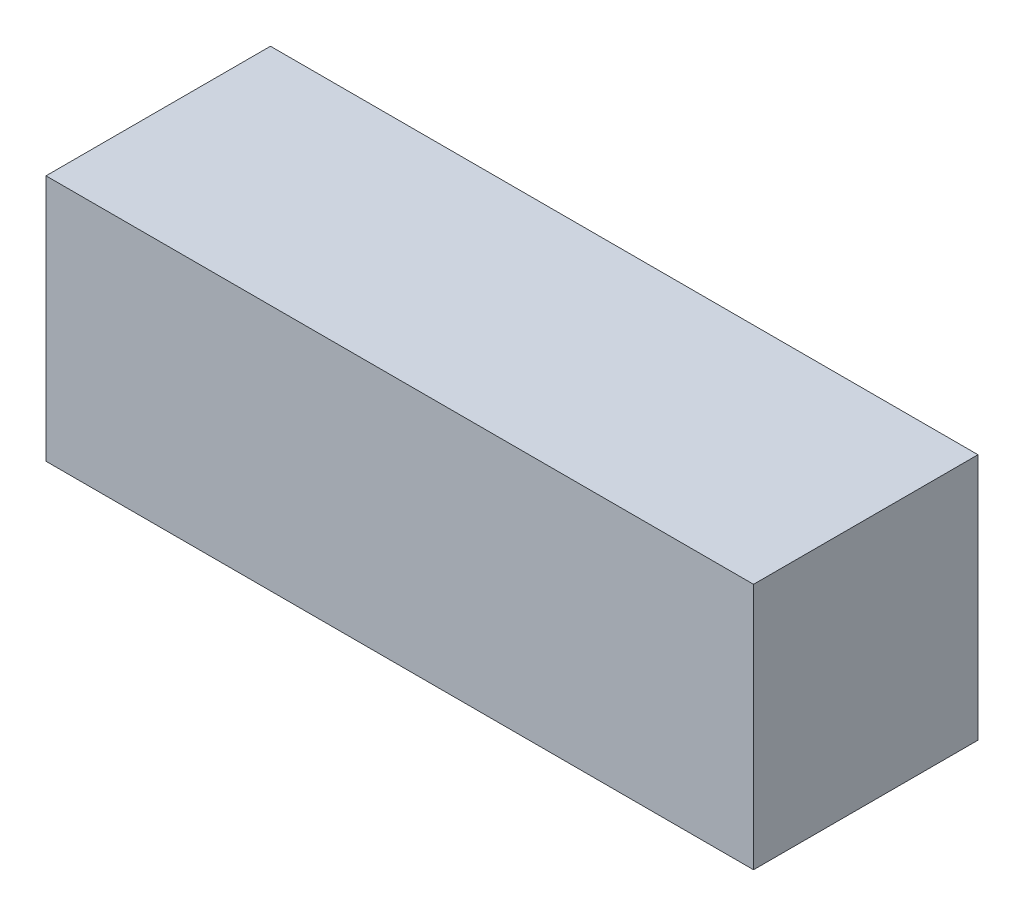
from build123d import *

# Parameters (mm, degrees)
SKETCH1_W           = 53.6448
SKETCH1_H           = 17.018
BOSS_EXTRUDE1_DEPTH = 18.7452


with BuildPart() as part:
    # Sketch1 → Boss-Extrude1 (new body)
    with BuildSketch(Plane(origin=(0, 0, 0), x_dir=(1, 0, 0), z_dir=(0, 1, 0))):
        Rectangle(SKETCH1_W, SKETCH1_H)
    extrude(amount=BOSS_EXTRUDE1_DEPTH)


solid = part.part
